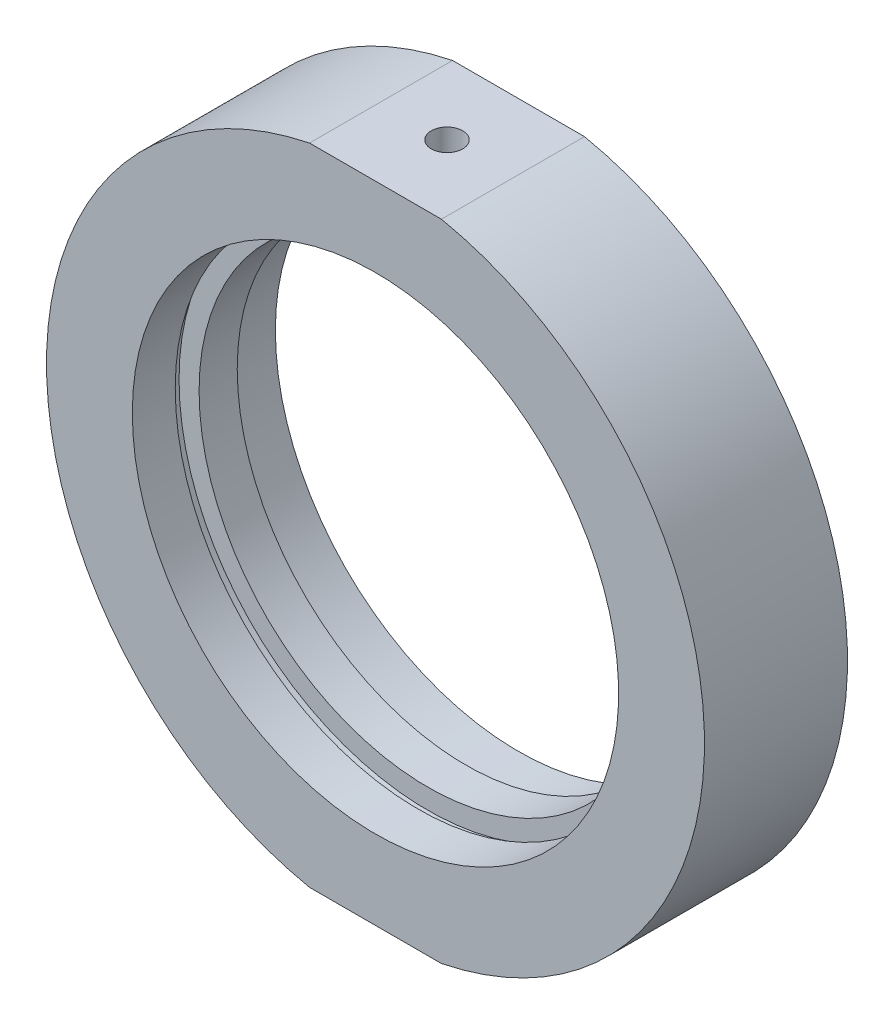
from build123d import *

# Parameters (mm, degrees)
SKETCH_2_W             = 64.02174429
SKETCH_2_H             = 9.248919907
CUT_EXTRUDE_1_DEPTH    = 49
HOLE_WIZARD_M4_2_D     = 3.3
HOLE_WIZARD_M4_2_DEPTH = 5.5
HOLE_WIZARD_M4_2_TIP   = 0.991420021
HOLE_WIZARD_M6_2_D     = 5
HOLE_WIZARD_M6_2_DEPTH = 5.5
HOLE_WIZARD_M6_2_TIP   = 1.502151548


with BuildPart() as part:
    # 草图1 → 旋转1 (revolve)
    with BuildSketch(Plane(origin=(0, 0, 0), x_dir=(1, 0, 0), z_dir=(0, 1, 0)), mode=Mode.PRIVATE) as revolve_1_sk:
        Polygon((34.5, 7.5), (34.5, -7.5), (25.5, -7.5), (25.5, -3), (26.1, -3), (26.1, -2), (25.5, -2), (24, -2), (24, 2), (25.5, 2), (26.1, 2), (26.1, 3), (25.5, 3), (25.5, 7.5), align=None)
    revolve(revolve_1_sk.sketch.rotate(Axis((0, 0, -31.9390681), (0, 0, 1)), 180), axis=Axis((0, 0, -31.9390681), (0, 0, 1)))  # turned: the seam where the file's is

    # 草图2 → 切除-拉伸1 (cut)
    with BuildSketch(Plane.XY.offset(7.5)):
        with Locations((-1.141100508, 38.424459954)):
            Rectangle(SKETCH_2_W, SKETCH_2_H)
        with Locations((-1.141100508, -38.424459954)):
            Rectangle(SKETCH_2_W, SKETCH_2_H)
    extrude(amount=-CUT_EXTRUDE_1_DEPTH, mode=Mode.SUBTRACT)

    # M4 螺纹孔2
    with Locations(Plane(origin=(0, 33.8, 0), x_dir=(1, 0, 0), z_dir=(0, 1, 0))):
        with Locations((0, 0)):
            Hole(HOLE_WIZARD_M4_2_D / 2, depth=HOLE_WIZARD_M4_2_DEPTH)
            with Locations((0, 0, -(HOLE_WIZARD_M4_2_DEPTH + HOLE_WIZARD_M4_2_TIP / 2))):  # 118° drill point
                Cone(0, HOLE_WIZARD_M4_2_D / 2, HOLE_WIZARD_M4_2_TIP, mode=Mode.SUBTRACT)

    # M6 螺纹孔2
    with Locations(Plane(origin=(0, -33.8, 0), x_dir=(-1, 0, 0), z_dir=(0, -1, 0))):
        with Locations((0, 0)):
            Hole(HOLE_WIZARD_M6_2_D / 2, depth=HOLE_WIZARD_M6_2_DEPTH)
            with Locations((0, 0, -(HOLE_WIZARD_M6_2_DEPTH + HOLE_WIZARD_M6_2_TIP / 2))):  # 118° drill point
                Cone(0, HOLE_WIZARD_M6_2_D / 2, HOLE_WIZARD_M6_2_TIP, mode=Mode.SUBTRACT)


solid = part.part
